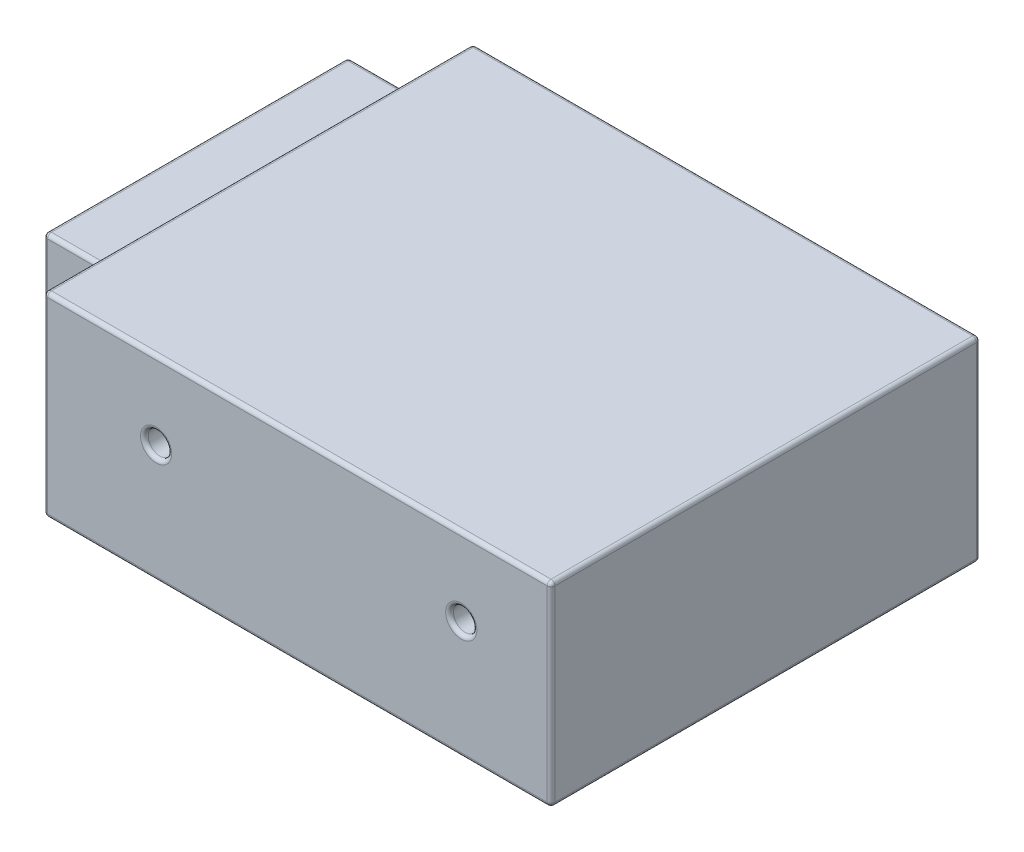
from build123d import *

# Parameters (mm, degrees)
SKETCH1_W           = 65
SKETCH1_H           = 55
BOSS_EXTRUDE1_DEPTH = 25
SKETCH2_R           = 1.5
CUT_EXTRUDE1_DEPTH  = 5
SKETCH3_R           = 1.5
CUT_EXTRUDE2_DEPTH  = 5
SKETCH4_W           = 39
SKETCH4_H           = 11.5
BOSS_EXTRUDE2_DEPTH = 13
FILLET1_R           = 0.5
SKETCH5_R           = 3.5
BOSS_EXTRUDE3_DEPTH = 2


with BuildPart() as part:
    # Sketch1 → Boss-Extrude1 (new body)
    with BuildSketch(Plane(origin=(0, 0, 0), x_dir=(1, 0, 0), z_dir=(0, 1, 0))):
        Rectangle(SKETCH1_W, SKETCH1_H)
    extrude(amount=BOSS_EXTRUDE1_DEPTH)

    # Sketch2 → Cut-Extrude1 (cut)
    with BuildSketch(Plane.XZ):
        with Locations((17.85, 2.25)):
            Circle(SKETCH2_R)
        with Locations((-21.25, 2.25)):
            Circle(SKETCH2_R)
    extrude(amount=-CUT_EXTRUDE1_DEPTH, mode=Mode.SUBTRACT)

    # Sketch3 → Cut-Extrude2 (cut)
    with BuildSketch(Plane.XY.offset(27.5)):
        with Locations((21, 15.1)):
            Circle(SKETCH3_R)
        with Locations((-18.1, 15.1)):
            Circle(SKETCH3_R)
    extrude(amount=-CUT_EXTRUDE2_DEPTH, mode=Mode.SUBTRACT)

    # Sketch4 → Boss-Extrude2 (add)
    with BuildSketch(Plane.ZY.offset(32.5)):
        with Locations((-5, 12.75)):
            Rectangle(SKETCH4_W, SKETCH4_H)
    extrude(amount=BOSS_EXTRUDE2_DEPTH)

    # Fillet1
    fillet1_edges = [part.edges().sort_by_distance(p)[0] for p in [
        (-32.5, 25, 0),
        (16.35, 0, 2.25),
        (0, 25, 27.5),
        (-22.75, 0, 2.25),
        (19.5, 15.1, 27.5),
        (-19.6, 15.1, 27.5),
        (-32.5, 12.75, 14.5),
        (-39, 7, 14.5),
        (-32.5, 18.5, -5),
        (-39, 18.5, 14.5),
        (-32.5, 12.75, -24.5),
        (-39, 18.5, -24.5),
        (-32.5, 7, -5),
        (-39, 7, -24.5),
        (-45.5, 12.75, 14.5),
        (-45.5, 18.5, -5),
        (-45.5, 12.75, -24.5),
        (-45.5, 7, -5),
        (32.5, 25, 0),
        (0, 0, 27.5),
        (-32.5, 0, 0),
        (0, 0, -27.5),
        (32.5, 0, 0),
        (32.5, 12.5, 27.5),
        (-32.5, 12.5, 27.5),
        (-32.5, 12.5, -27.5),
        (32.5, 12.5, -27.5),
        (0, 25, -27.5),
    ]]
    fillet(fillet1_edges, radius=FILLET1_R)

    # Sketch5 → Boss-Extrude3 (add)
    with BuildSketch(Plane.ZY.offset(32.5)):
        with Locations((20, 11.5)):
            Circle(SKETCH5_R)
    extrude(amount=BOSS_EXTRUDE3_DEPTH)


solid = part.part
